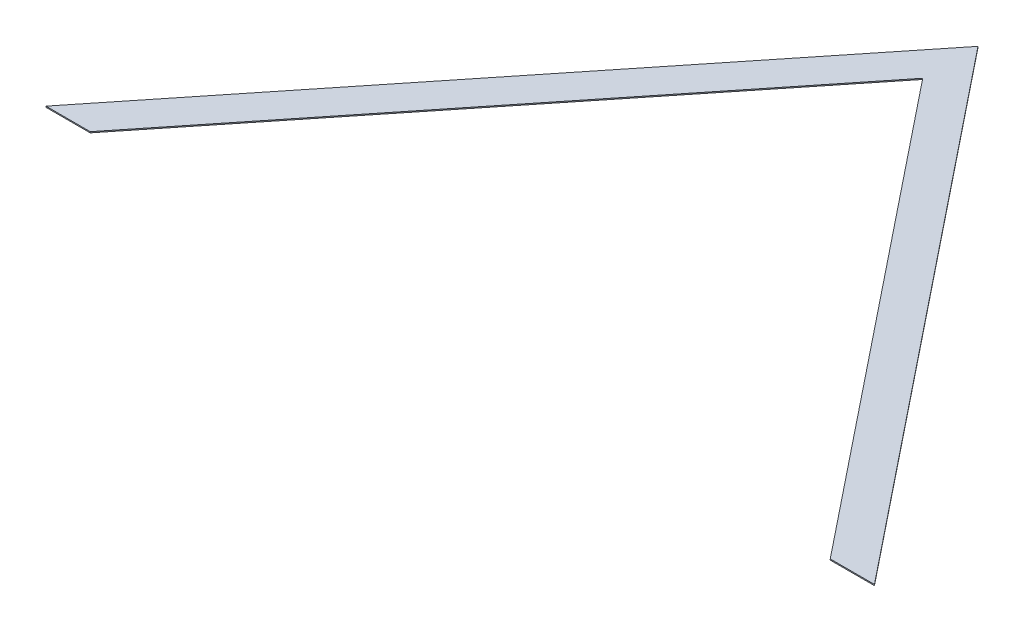
from build123d import *

# Parameters (mm, degrees)
BOSS_EXTRUDE1_DEPTH = 1.5875


with BuildPart() as part:
    # Sketch1 → Boss-Extrude1 (new body)
    with BuildSketch(Plane(origin=(0, 0, 0), x_dir=(1, 0, 0), z_dir=(0, 1, 0))):
        Polygon((609.6, 0), (0, 762), (-609.6, 0), (-544.544257748, 0), (0, 680.680322185), (544.544257748, 0), align=None)
    extrude(amount=BOSS_EXTRUDE1_DEPTH)


solid = part.part
